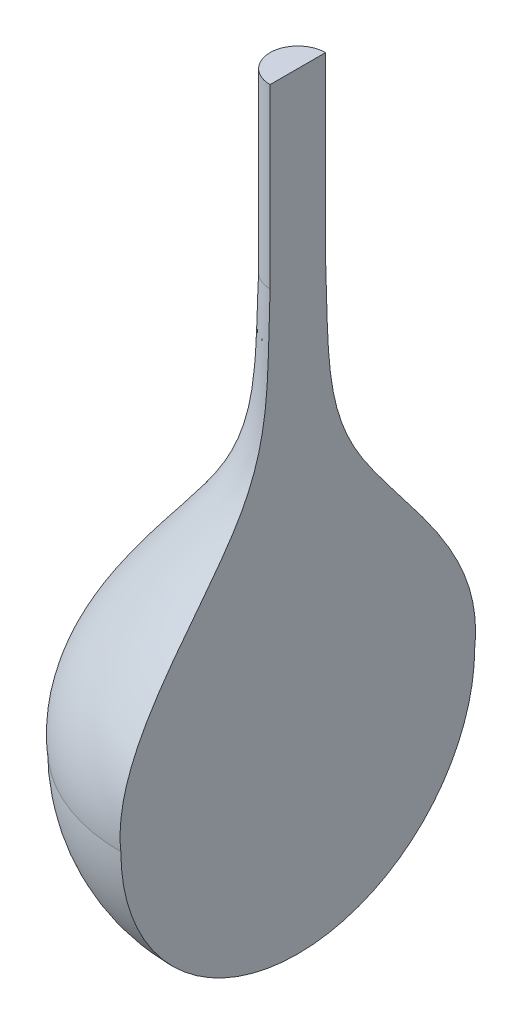
from build123d import *

# Parameters (mm, degrees)
SKETCH2_R               = 2.35
BOSS_EXTRUDE1_DEPTH     = 15
CUT_EXTRUDE2_DEPTH      = 25
CUT_EXTRUDE2_DEPTH_BACK = 25


with BuildPart() as part:
    # Sketch1 → Revolve2 (revolve)
    with BuildSketch(Plane.XY, mode=Mode.PRIVATE) as revolve2_sk:
        with BuildLine():
            Line((0, 27.986111111), (0, -7.013888889))
            Line((0, -7.013888889), (0, -22.013888889))
            ThreePointArc((0, -22.013888889), (10.606601718, -17.620490607), (15, -7.013888889))
            add(Edge.make_bspline(
                [(2.35, 27.986111111), (2.599847264, 21.390422987), (1.849692868, 12.096697956), (15.855089794, 0.539943119), (15, -7.013888889)],
                knots=[0, 0, 0, 0, 0.452531855, 1, 1, 1, 1], degree=3))
            Line((2.35, 27.986111111), (0, 27.986111111))
        make_face()
    revolve(revolve2_sk.sketch.rotate(Axis((0, 27.986111111, 0), (0, -1, 0)), 180), axis=Axis((0, 27.986111111, 0), (0, -1, 0)))  # turned: the seam where the file's is

    # Sketch2 → Boss-Extrude1 (add)
    with BuildSketch(Plane(origin=(0, 27.986111111, 0), x_dir=(1, 0, 0), z_dir=(0, 1, 0))):
        with Locations(Location((0, 0, 0), (0, 0, 180))):  # turned: the seam where the file's is
            Circle(SKETCH2_R)
    extrude(amount=BOSS_EXTRUDE1_DEPTH)

    # Sketch3 → Cut-Extrude2 (cut, two sides)
    with BuildSketch(Plane.XY) as cut_extrude2_sk:
        Polygon((0, 42.986111111), (0, 27.986111111), (0, -22.013888889), (0, -24.288490859), (33.029158628, -24.288490859), (33.029158628, 42.986111111), align=None)
    extrude(amount=CUT_EXTRUDE2_DEPTH, mode=Mode.SUBTRACT)
    extrude(cut_extrude2_sk.sketch, amount=-CUT_EXTRUDE2_DEPTH_BACK, mode=Mode.SUBTRACT)


solid = part.part
